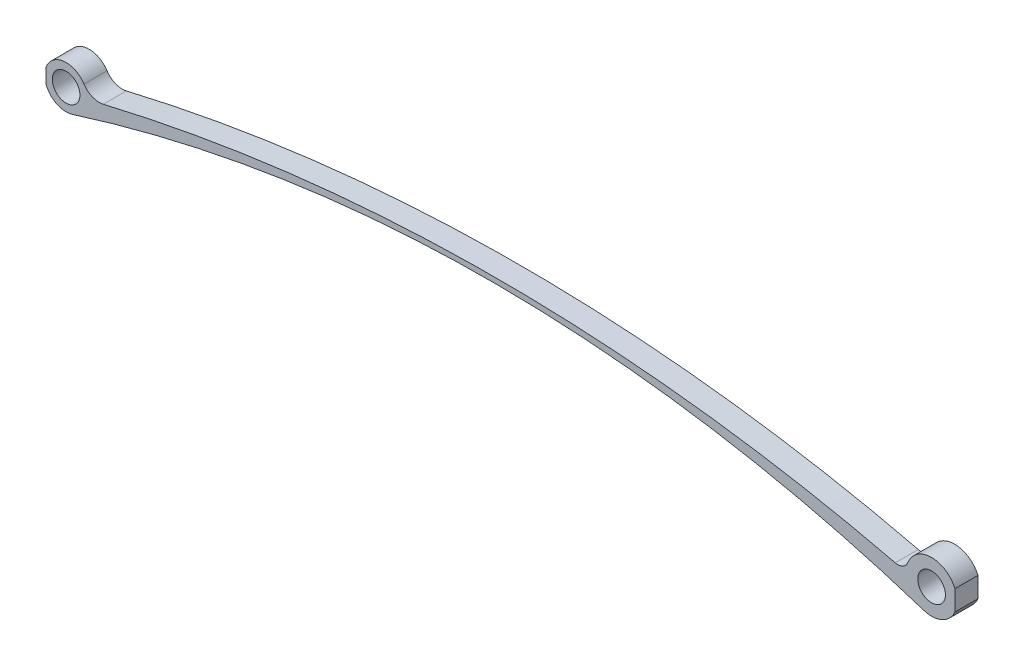
from build123d import *

# Parameters (mm, degrees)
SZKIC1_R                    = 3.000000079
DODANIE_WYCI_GNI_CIE1_DEPTH = 5
SZKIC2_W                    = 1.618528634
SZKIC2_H                    = 7.505645785
SZKIC2_W_2                  = 0.651830256
SZKIC2_H_2                  = 5.051684483
WYTNIJ_WYCI_GNI_CIE3_DEPTH  = 6


with BuildPart() as part:
    # Szkic1 → Dodanie-wyciągnięcie1 (new body)
    with BuildSketch(Plane.XY):
        with BuildLine():
            ThreePointArc((186.046385231, -5.249250637), (192.755682752, 2.359335985), (182.617563383, 2.007484775))
            ThreePointArc((182.617563383, 2.007484775), (181.515861501, 0.778055334), (179.877474491, 0.575739249))
            ThreePointArc((179.877474491, 0.575739249), (94.00112496, 10.812901668), (8.093987839, 0.837396921))
            ThreePointArc((8.093987839, 0.837396921), (5.72392167, 1.013694647), (3.88824622, 2.523194623))
            ThreePointArc((3.88824622, 2.523194623), (-4.363457527, 1.563716145), (1.400567067, -4.418527092))
            ThreePointArc((1.400567067, -4.418527092), (93.788687704, 9.660753619), (186.046385231, -5.249250637))
        make_face()
        Circle(SZKIC1_R, mode=Mode.SUBTRACT)
        with Locations((187.7624, 0)):
            Circle(SZKIC1_R, mode=Mode.SUBTRACT)
    extrude(amount=DODANIE_WYCI_GNI_CIE1_DEPTH)

    # Szkic2 → Wytnij-wyciągnięcie3 (cut, through all)
    with BuildSketch(Plane.XY):
        with Locations((193.638606269, 0.381285041)):
            Rectangle(SZKIC2_W, SZKIC2_H)
        with Locations((-4.682734605, -0.038745932)):
            Rectangle(SZKIC2_W_2, SZKIC2_H_2)
    extrude(amount=WYTNIJ_WYCI_GNI_CIE3_DEPTH, mode=Mode.SUBTRACT)


solid = part.part
